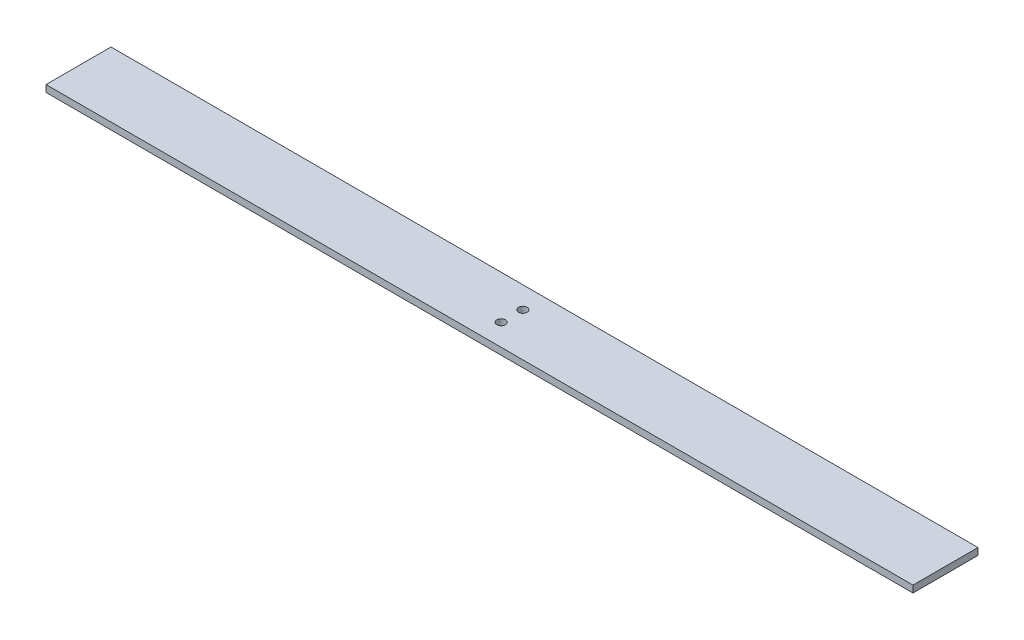
from build123d import *

# Parameters (mm, degrees)
SKETCH1_W           = 400
SKETCH1_H           = 30
BOSS_EXTRUDE1_DEPTH = 3.175
SKETCH2_R           = 2
CUT_EXTRUDE1_DEPTH  = 3.175


with BuildPart() as part:
    # Sketch1 → Boss-Extrude1 (new body)
    with BuildSketch(Plane(origin=(0, 0, 0), x_dir=(1, 0, 0), z_dir=(0, 1, 0))):
        with Locations((24.052868647, 24.698962692)):
            Rectangle(SKETCH1_W, SKETCH1_H)
    extrude(amount=BOSS_EXTRUDE1_DEPTH)

    # Sketch2 → Cut-Extrude1 (cut)
    with BuildSketch(Plane(origin=(0, 3.175, 0), x_dir=(1, 0, 0), z_dir=(0, 1, 0))):
        with Locations((24.052868647, 29.698962692)):
            Circle(SKETCH2_R)
        with Locations((24.052868647, 19.698962692)):
            Circle(SKETCH2_R)
    extrude(amount=-CUT_EXTRUDE1_DEPTH, mode=Mode.SUBTRACT)


solid = part.part
